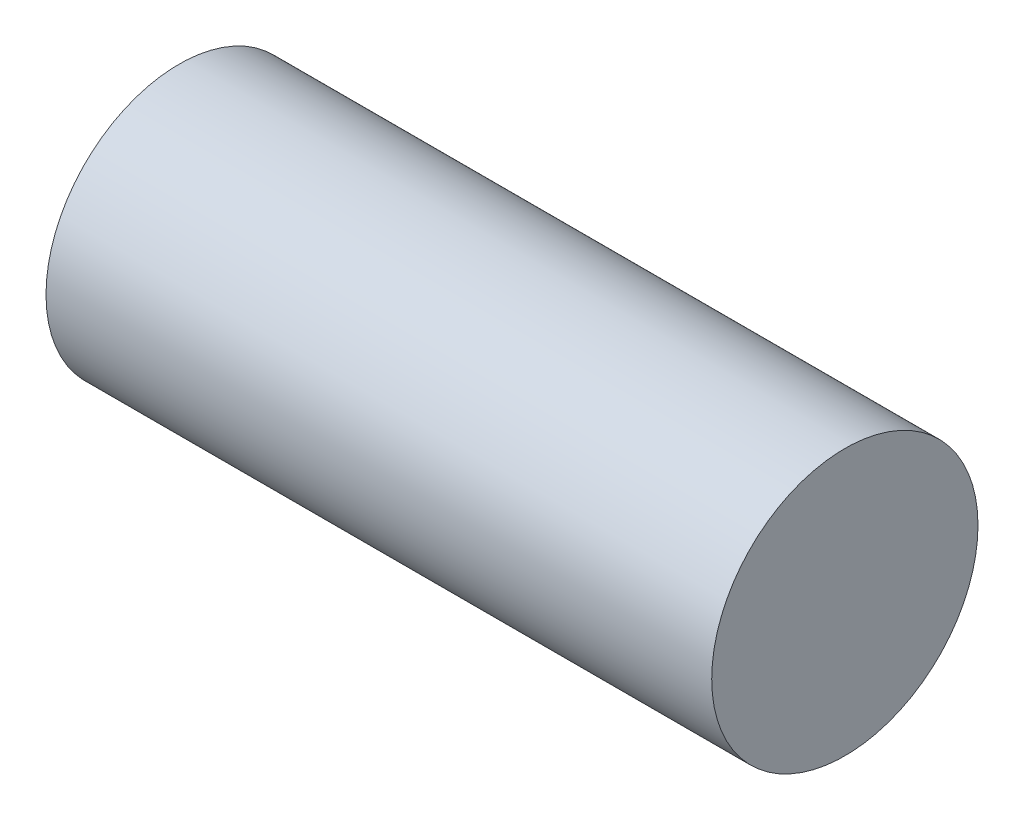
from build123d import *

# Parameters (mm, degrees)
RIVETPROFILE_R      = 40
BOSS_EXTRUDE1_DEPTH = 200


with BuildPart() as part:
    # RivetProfile → Boss-Extrude1 (new body)
    with BuildSketch(Plane(origin=(0, 0, 0), x_dir=(0, 0, -1), z_dir=(1, 0, 0))):
        Circle(RIVETPROFILE_R)
    extrude(amount=BOSS_EXTRUDE1_DEPTH)


solid = part.part
